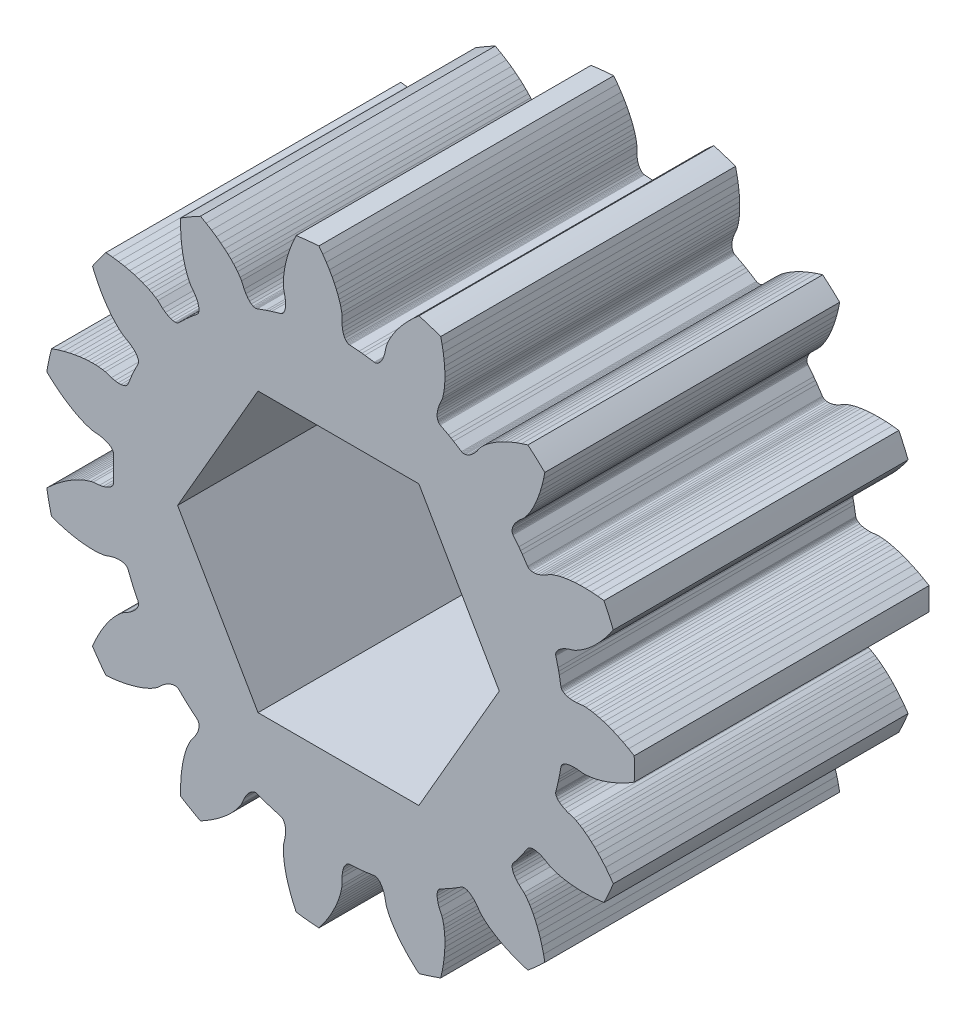
from build123d import *

# Parameters (mm, degrees)
BOSS_EXTRUDE1_DEPTH     = 6.35
CUT_EXTRUDE1_DEPTH      = 20.098065115
CUT_EXTRUDE1_DEPTH_BACK = 20.098065115


with BuildPart() as part:
    # Model → Boss-Extrude1 (new, symmetric)
    with BuildSketch(Plane.XY):
        with BuildLine():
            Line((11.6767396, 4.5035235), (11.5102774, 4.2884543))
            Line((11.5102774, 4.2884543), (11.3474436, 4.0953698))
            Line((11.3474436, 4.0953698), (11.189078, 3.9227721))
            Line((11.189078, 3.9227721), (11.0381832, 3.7714935))
            Line((11.0381832, 3.7714935), (10.8924568, 3.6371189))
            Line((10.8924568, 3.6371189), (10.7549211, 3.520628))
            Line((10.7549211, 3.520628), (10.6294039, 3.4230594))
            Line((10.6294039, 3.4230594), (10.5151057, 3.3415851))
            Line((10.5151057, 3.3415851), (10.4118689, 3.2743006))
            Line((10.4118689, 3.2743006), (10.2465352, 3.1803221))
            Line((10.2465352, 3.1803221), (10.1399378, 3.1308686))
            Line((10.1399378, 3.1308686), (9.8729831, 3.0466553))
            Line((9.8729831, 3.0466553), (9.731807, 2.9862021))
            Line((9.731807, 2.9862021), (9.6130244, 2.9201014))
            Line((9.6130244, 2.9201014), (9.516822, 2.8501205))
            Line((9.516822, 2.8501205), (9.4432844, 2.7780258))
            Line((9.4432844, 2.7780258), (9.3923921, 2.7055918))
            Line((9.3923921, 2.7055918), (9.3753911, 2.6698051))
            Line((9.3753911, 2.6698051), (9.3639924, 2.6345957))
            Line((9.3639924, 2.6345957), (9.3581623, 2.6001713))
            Line((9.3581623, 2.6001713), (9.3578605, 2.5667687))
            Line((9.3578605, 2.5667687), (9.3630336, 2.5345911))
            Line((9.3630336, 2.5345911), (9.460687, 2.1414942))
            Line((9.460687, 2.1414942), (9.4880317, 2.0167434))
            Line((9.4880317, 2.0167434), (9.5137918, 1.8916558))
            Line((9.5137918, 1.8916558), (9.5844679, 1.4928247))
            Line((9.5844679, 1.4928247), (9.5928298, 1.4613249))
            Line((9.5928298, 1.4613249), (9.6066916, 1.4309328))
            Line((9.6066916, 1.4309328), (9.6260194, 1.4018559))
            Line((9.6260194, 1.4018559), (9.6507535, 1.3743268))
            Line((9.6507535, 1.3743268), (9.6808405, 1.3485489))
            Line((9.6808405, 1.3485489), (9.7567944, 1.303077))
            Line((9.7567944, 1.303077), (9.853298, 1.2671256))
            Line((9.853298, 1.2671256), (9.969647, 1.2423239))
            Line((9.969647, 1.2423239), (10.1050459, 1.2302511))
            Line((10.1050459, 1.2302511), (10.2586052, 1.2324459))
            Line((10.2586052, 1.2324459), (10.5367331, 1.2640935))
            Line((10.5367331, 1.2640935), (10.6542293, 1.2622725))
            Line((10.6542293, 1.2622725), (10.8434936, 1.2436662))
            Line((10.8434936, 1.2436662), (10.9651721, 1.2241889))
            Line((10.9651721, 1.2241889), (11.1027273, 1.1962477))
            Line((11.1027273, 1.1962477), (11.2570777, 1.1581668))
            Line((11.2570777, 1.1581668), (11.4301039, 1.1076879))
            Line((11.4301039, 1.1076879), (11.6178867, 1.0442028))
            Line((11.6178867, 1.0442028), (11.8172666, 0.9673774))
            Line((11.8172666, 0.9673774), (12.0321425, 0.8741146))
            Line((12.0321425, 0.8741146), (12.2594331, 0.7639537))
            Line((12.2594331, 0.7639537), (12.4989804, 0.6351845))
            Line((12.4989804, 0.6351845), (12.740472, 0.4919755))
            ThreePointArc((12.740472, 0.4919755), (12.749967296, 0), (12.740472, -0.4919755))
            Line((12.740472, -0.4919755), (12.4989804, -0.6351845))
            Line((12.4989804, -0.6351845), (12.2594331, -0.7639537))
            Line((12.2594331, -0.7639537), (12.0321425, -0.8741146))
            Line((12.0321425, -0.8741146), (11.8172666, -0.9673774))
            Line((11.8172666, -0.9673774), (11.6178867, -1.0442028))
            Line((11.6178867, -1.0442028), (11.4301039, -1.1076879))
            Line((11.4301039, -1.1076879), (11.2570777, -1.1581668))
            Line((11.2570777, -1.1581668), (11.1027273, -1.1962477))
            Line((11.1027273, -1.1962477), (10.9651721, -1.2241889))
            Line((10.9651721, -1.2241889), (10.8434936, -1.2436662))
            Line((10.8434936, -1.2436662), (10.6542293, -1.2622725))
            Line((10.6542293, -1.2622725), (10.5367331, -1.2640935))
            Line((10.5367331, -1.2640935), (10.2586052, -1.2324459))
            Line((10.2586052, -1.2324459), (10.1050459, -1.2302511))
            Line((10.1050459, -1.2302511), (9.969647, -1.2423239))
            Line((9.969647, -1.2423239), (9.853298, -1.2671256))
            Line((9.853298, -1.2671256), (9.7567944, -1.303077))
            Line((9.7567944, -1.303077), (9.6808405, -1.3485489))
            Line((9.6808405, -1.3485489), (9.6507535, -1.3743268))
            Line((9.6507535, -1.3743268), (9.6260194, -1.4018559))
            Line((9.6260194, -1.4018559), (9.6066916, -1.4309328))
            Line((9.6066916, -1.4309328), (9.5928298, -1.4613249))
            Line((9.5928298, -1.4613249), (9.5844679, -1.4928247))
            Line((9.5844679, -1.4928247), (9.5137918, -1.8916558))
            Line((9.5137918, -1.8916558), (9.4880317, -2.0167434))
            Line((9.4880317, -2.0167434), (9.460687, -2.1414942))
            Line((9.460687, -2.1414942), (9.3630336, -2.5345911))
            Line((9.3630336, -2.5345911), (9.3578605, -2.5667687))
            Line((9.3578605, -2.5667687), (9.3581623, -2.6001713))
            Line((9.3581623, -2.6001713), (9.3639924, -2.6345957))
            Line((9.3639924, -2.6345957), (9.3753911, -2.6698051))
            Line((9.3753911, -2.6698051), (9.3923921, -2.7055918))
            Line((9.3923921, -2.7055918), (9.4432844, -2.7780258))
            Line((9.4432844, -2.7780258), (9.516822, -2.8501205))
            Line((9.516822, -2.8501205), (9.6130244, -2.9201014))
            Line((9.6130244, -2.9201014), (9.731807, -2.9862021))
            Line((9.731807, -2.9862021), (9.8729831, -3.0466553))
            Line((9.8729831, -3.0466553), (10.1399378, -3.1308686))
            Line((10.1399378, -3.1308686), (10.2465352, -3.1803221))
            Line((10.2465352, -3.1803221), (10.4118689, -3.2743006))
            Line((10.4118689, -3.2743006), (10.5151057, -3.3415851))
            Line((10.5151057, -3.3415851), (10.6294039, -3.4230594))
            Line((10.6294039, -3.4230594), (10.7549211, -3.520628))
            Line((10.7549211, -3.520628), (10.8924568, -3.6371189))
            Line((10.8924568, -3.6371189), (11.0381832, -3.7714935))
            Line((11.0381832, -3.7714935), (11.189078, -3.9227721))
            Line((11.189078, -3.9227721), (11.3474436, -4.0953698))
            Line((11.3474436, -4.0953698), (11.5102774, -4.2884543))
            Line((11.5102774, -4.2884543), (11.6767396, -4.5035235))
            Line((11.6767396, -4.5035235), (11.8391048, -4.7325748))
            ThreePointArc((11.8391048, -4.7325748), (11.647674735, -5.185878885), (11.4388959, -5.6314588))
            Line((11.4388959, -5.6314588), (11.160034, -5.6640632))
            Line((11.160034, -5.6640632), (10.8888215, -5.6842671))
            Line((10.8888215, -5.6842671), (10.6363747, -5.6924567))
            Line((10.6363747, -5.6924567), (10.4021424, -5.6902585))
            Line((10.4021424, -5.6902585), (10.1887521, -5.679347))
            Line((10.1887521, -5.679347), (9.9913823, -5.6609653))
            Line((9.9913823, -5.6609653), (9.8127834, -5.636704))
            Line((9.8127834, -5.636704), (9.6562884, -5.6087127))
            Line((9.6562884, -5.6087127), (9.5192607, -5.5782895))
            Line((9.5192607, -5.5782895), (9.4001797, -5.5465918))
            Line((9.4001797, -5.5465918), (9.2197103, -5.4866088))
            Line((9.2197103, -5.4866088), (9.1116315, -5.4404823))
            Line((9.1116315, -5.4404823), (8.8704213, -5.298446))
            Line((8.8704213, -5.298446), (8.7310306, -5.2339828))
            Line((8.7310306, -5.2339828), (8.6024271, -5.1899402))
            Line((8.6024271, -5.1899402), (8.4860492, -5.1652742))
            Line((8.4860492, -5.1652742), (8.3832661, -5.1588659))
            Line((8.3832661, -5.1588659), (8.2953836, -5.1695133))
            Line((8.2953836, -5.1695133), (8.257413, -5.1808251))
            Line((8.257413, -5.1808251), (8.2236201, -5.1959139))
            Line((8.2236201, -5.1959139), (8.1941367, -5.2146157))
            Line((8.1941367, -5.2146157), (8.1691117, -5.2367421))
            Line((8.1691117, -5.2367421), (8.1486606, -5.2621176))
            Line((8.1486606, -5.2621176), (7.9218756, -5.5977213))
            Line((7.9218756, -5.5977213), (7.8474648, -5.7015169))
            Line((7.8474648, -5.7015169), (7.7717435, -5.8043604))
            Line((7.7717435, -5.8043604), (7.5226458, -6.123753))
            Line((7.5226458, -6.123753), (7.5048321, -6.1510446))
            Line((7.5048321, -6.1510446), (7.4915217, -6.1816822))
            Line((7.4915217, -6.1816822), (7.4828461, -6.2155018))
            Line((7.4828461, -6.2155018), (7.4789384, -6.2523034))
            Line((7.4789384, -6.2523034), (7.4799138, -6.2919111))
            Line((7.4799138, -6.2919111), (7.4969447, -6.3787826))
            Line((7.4969447, -6.3787826), (7.5348011, -6.4745549))
            Line((7.5348011, -6.4745549), (7.5942226, -6.5776146))
            Line((7.5942226, -6.5776146), (7.6758502, -6.6863139))
            Line((7.6758502, -6.6863139), (7.7802325, -6.7989622))
            Line((7.7802325, -6.7989622), (7.9898551, -6.984475))
            Line((7.9898551, -6.984475), (8.0671222, -7.0730102))
            Line((8.0671222, -7.0730102), (8.1799375, -7.2261111))
            Line((8.1799375, -7.2261111), (8.246882, -7.3295686))
            Line((8.246882, -7.3295686), (8.31816, -7.4504884))
            Line((8.31816, -7.4504884), (8.3931409, -7.5906742))
            Line((8.3931409, -7.5906742), (8.4714049, -7.7530347))
            Line((8.4714049, -7.7530347), (8.5498775, -7.9350643))
            Line((8.5498775, -7.9350643), (8.6261962, -8.1346387))
            Line((8.6261962, -8.1346387), (8.7006686, -8.3567276))
            Line((8.7006686, -8.3567276), (8.7708902, -8.5993495))
            Line((8.7708902, -8.5993495), (8.8354844, -8.8635313))
            Line((8.8354844, -8.8635313), (8.8906488, -9.13882))
            ThreePointArc((8.8906488, -9.13882), (8.531393343, -9.47507223), (8.1594307, -9.7972117))
            Line((8.1594307, -9.7972117), (7.8914163, -9.713574))
            Line((7.8914163, -9.713574), (7.6354337, -9.6217191))
            Line((7.6354337, -9.6217191), (7.4014811, -9.5265213))
            Line((7.4014811, -9.5265213), (7.1883932, -9.4292423))
            Line((7.1883932, -9.4292423), (6.9978897, -9.3324805))
            Line((6.9978897, -9.3324805), (6.8250599, -9.2354105))
            Line((6.8250599, -9.2354105), (6.6717696, -9.1406039))
            Line((6.6717696, -9.1406039), (6.5401894, -9.0513803))
            Line((6.5401894, -9.0513803), (6.4273826, -8.9678532))
            Line((6.4273826, -8.9678532), (6.3314894, -8.8904613))
            Line((6.3314894, -8.8904613), (6.1910196, -8.7622605))
            Line((6.1910196, -8.7622605), (6.1110461, -8.6761623))
            Line((6.1110461, -8.6761623), (5.948461, -8.4482966))
            Line((5.948461, -8.4482966), (5.8473407, -8.3327113))
            Line((5.8473407, -8.3327113), (5.7477694, -8.2401686))
            Line((5.7477694, -8.2401686), (5.6514854, -8.1702999))
            Line((5.6514854, -8.1702999), (5.5601949, -8.12264))
            Line((5.5601949, -8.12264), (5.4755795, -8.0966219))
            Line((5.4755795, -8.0966219), (5.4362907, -8.0915117))
            Line((5.4362907, -8.0915117), (5.3992822, -8.0915512))
            Line((5.3992822, -8.0915512), (5.3647411, -8.0966441))
            Line((5.3647411, -8.0966441), (5.33288, -8.1066791))
            Line((5.33288, -8.1066791), (5.3038758, -8.1215424))
            Line((5.3038758, -8.1215424), (4.9601951, -8.3358899))
            Line((4.9601951, -8.3358899), (4.85, -8.4004464))
            Line((4.85, -8.4004464), (4.7389949, -8.4635999))
            Line((4.7389949, -8.4635999), (4.3815242, -8.6540624))
            Line((4.3815242, -8.6540624), (4.35415, -8.6717491))
            Line((4.35415, -8.6717491), (4.3295289, -8.6943241))
            Line((4.3295289, -8.6943241), (4.3078478, -8.7216912))
            Line((4.3078478, -8.7216912), (4.2893093, -8.7537217))
            Line((4.2893093, -8.7537217), (4.2740905, -8.7903019))
            Line((4.2740905, -8.7903019), (4.2543151, -8.87659))
            Line((4.2543151, -8.87659), (4.2499446, -8.9794799))
            Line((4.2499446, -8.9794799), (4.2623106, -9.0977986))
            Line((4.2623106, -9.0977986), (4.2926693, -9.2303013))
            Line((4.2926693, -9.2303013), (4.342209, -9.3756666))
            Line((4.342209, -9.3756666), (4.4582539, -9.6304023))
            Line((4.4582539, -9.6304023), (4.4928304, -9.7427105))
            Line((4.4928304, -9.7427105), (4.5336206, -9.9284613))
            Line((4.5336206, -9.9284613), (4.5526974, -10.0502032))
            Line((4.5526974, -10.0502032), (4.5686306, -10.1896603))
            Line((4.5686306, -10.1896603), (4.5801104, -10.3482239))
            Line((4.5801104, -10.3482239), (4.5855701, -10.5283805))
            Line((4.5855701, -10.5283805), (4.5832203, -10.7265905))
            Line((4.5832203, -10.7265905), (4.5717668, -10.9399523))
            Line((4.5717668, -10.9399523), (4.5494689, -11.1731313))
            Line((4.5494689, -11.1731313), (4.5149363, -11.4233391))
            Line((4.5149363, -11.4233391), (4.4664937, -11.690954))
            Line((4.4664937, -11.690954), (4.4049189, -11.9648801))
            ThreePointArc((4.4049189, -11.9648801), (3.939956558, -12.125939465), (3.4691258, -12.2689377))
            Line((3.4691258, -12.2689377), (3.258301, -12.0835196))
            Line((3.258301, -12.0835196), (3.06181, -11.8954884))
            Line((3.06181, -11.8954884), (2.8868041, -11.7133638))
            Line((2.8868041, -11.7133638), (2.7317056, -11.5378244))
            Line((2.7317056, -11.5378244), (2.5970286, -11.3719433))
            Line((2.5970286, -11.3719433), (2.4786226, -11.2129692))
            Line((2.4786226, -11.2129692), (2.3771463, -11.0640104))
            Line((2.3771463, -11.0640104), (2.2932323, -10.9289821))
            Line((2.2932323, -10.9289821), (2.2241517, -10.8067936))
            Line((2.2241517, -10.8067936), (2.168027, -10.6970892))
            Line((2.168027, -10.6970892), (2.0918454, -10.5228378))
            Line((2.0918454, -10.5228378), (2.0538053, -10.411655))
            Line((2.0538053, -10.411655), (1.9979577, -10.1373601))
            Line((1.9979577, -10.1373601), (1.9525926, -9.9906383))
            Line((1.9525926, -9.9906383), (1.8992701, -9.865597))
            Line((1.8992701, -9.865597), (1.8397285, -9.7626066))
            Line((1.8397285, -9.7626066), (1.7757154, -9.6819359))
            Line((1.7757154, -9.6819359), (1.708998, -9.623751))
            Line((1.708998, -9.623751), (1.6751844, -9.6031024))
            Line((1.6751844, -9.6031024), (1.6413594, -9.5880858))
            Line((1.6413594, -9.5880858), (1.607733, -9.5786892))
            Line((1.607733, -9.5786892), (1.5745448, -9.5748975))
            Line((1.5745448, -9.5748975), (1.5420028, -9.5766789))
            Line((1.5420028, -9.5766789), (1.1408518, -9.6327075))
            Line((1.1408518, -9.6327075), (1.0139261, -9.6468624))
            Line((1.0139261, -9.6468624), (0.886831, -9.6594062))
            Line((0.886831, -9.6594062), (0.4827972, -9.6880059))
            Line((0.4827972, -9.6880059), (0.4505959, -9.6930293))
            Line((0.4505959, -9.6930293), (0.4189213, -9.7036383))
            Line((0.4189213, -9.7036383), (0.3879834, -9.7198209))
            Line((0.3879834, -9.7198209), (0.3580197, -9.7415419))
            Line((0.3580197, -9.7415419), (0.3292381, -9.7687696))
            Line((0.3292381, -9.7687696), (0.2760759, -9.8395543))
            Line((0.2760759, -9.8395543), (0.230234, -9.9317713))
            Line((0.230234, -9.9317713), (0.1934065, -10.0448905))
            Line((0.1934065, -10.0448905), (0.1672468, -10.1782857))
            Line((0.1672468, -10.1782857), (0.1533782, -10.3312332))
            Line((0.1533782, -10.3312332), (0.1557801, -10.6111455))
            Line((0.1557801, -10.6111455), (0.1416874, -10.7278077))
            Line((0.1416874, -10.7278077), (0.1033995, -10.9140903))
            Line((0.1033995, -10.9140903), (0.0713101, -11.0330664))
            Line((0.0713101, -11.0330664), (0.0291435, -11.1669474))
            Line((0.0291435, -11.1669474), (-0.0248628, -11.3164717))
            Line((-0.0248628, -11.3164717), (-0.0931514, -11.4832735))
            Line((-0.0931514, -11.4832735), (-0.1759173, -11.6633916))
            Line((-0.1759173, -11.6633916), (-0.2731627, -11.8536488))
            Line((-0.2731627, -11.8536488), (-0.3883753, -12.0575991))
            Line((-0.3883753, -12.0575991), (-0.521691, -12.2721296))
            Line((-0.521691, -12.2721296), (-0.6747944, -12.4969046))
            Line((-0.6747944, -12.4969046), (-0.8424615, -12.7221038))
            ThreePointArc((-0.8424615, -12.7221038), (-1.332734479, -12.680121632), (-1.8210224, -12.6192529))
            Line((-1.8210224, -12.6192529), (-1.9382041, -12.3641149))
            Line((-1.9382041, -12.3641149), (-2.0412284, -12.1124198))
            Line((-2.0412284, -12.1124198), (-2.1270275, -11.8748593))
            Line((-2.1270275, -11.8748593), (-2.1973187, -11.6514119))
            Line((-2.1973187, -11.6514119), (-2.2528824, -11.4450938))
            Line((-2.2528824, -11.4450938), (-2.296391, -11.2517037))
            Line((-2.296391, -11.2517037), (-2.3285073, -11.0743489))
            Line((-2.3285073, -11.0743489), (-2.3502456, -10.9168635))
            Line((-2.3502456, -10.9168635), (-2.3636553, -10.7771412))
            Line((-2.3636553, -10.7771412), (-2.370307, -10.6540933))
            Line((-2.370307, -10.6540933), (-2.3690279, -10.4639209))
            Line((-2.3690279, -10.4639209), (-2.3585571, -10.346878))
            Line((-2.3585571, -10.346878), (-2.2980106, -10.0735819))
            Line((-2.2980106, -10.0735819), (-2.2797766, -9.9210931))
            Line((-2.2797766, -9.9210931), (-2.2776302, -9.7851741))
            Line((-2.2776302, -9.7851741), (-2.2901342, -9.6668699))
            Line((-2.2901342, -9.6668699), (-2.3158013, -9.5671371))
            Line((-2.3158013, -9.5671371), (-2.3530848, -9.4868461))
            Line((-2.3530848, -9.4868461), (-2.3755765, -9.4542294))
            Line((-2.3755765, -9.4542294), (-2.4003694, -9.4267532))
            Line((-2.4003694, -9.4267532), (-2.4272667, -9.4044919))
            Line((-2.4272667, -9.4044919), (-2.4560434, -9.3875292))
            Line((-2.4560434, -9.3875292), (-2.4864966, -9.3759205))
            Line((-2.4864966, -9.3759205), (-2.8757551, -9.2639424))
            Line((-2.8757551, -9.2639424), (-2.9974648, -9.2252482))
            Line((-2.9974648, -9.2252482), (-3.118674, -9.1850133))
            Line((-3.118674, -9.1850133), (-3.4994098, -9.0468051))
            Line((-3.4994098, -9.0468051), (-3.5308704, -9.0382968))
            Line((-3.5308704, -9.0382968), (-3.5641216, -9.0351054))
            Line((-3.5641216, -9.0351054), (-3.5989669, -9.0373053))
            Line((-3.5989669, -9.0373053), (-3.6351748, -9.0449611))
            Line((-3.6351748, -9.0449611), (-3.6725426, -9.0581283))
            Line((-3.6725426, -9.0581283), (-3.7498994, -9.1011703))
            Line((-3.7498994, -9.1011703), (-3.8292861, -9.1667692))
            Line((-3.8292861, -9.1667692), (-3.9089394, -9.2551296))
            Line((-3.9089394, -9.2551296), (-3.9870942, -9.366352))
            Line((-3.9870942, -9.366352), (-4.0619732, -9.5004357))
            Line((-4.0619732, -9.5004357), (-4.1736295, -9.7571253))
            Line((-4.1736295, -9.7571253), (-4.2339546, -9.8579694))
            Line((-4.2339546, -9.8579694), (-4.3447003, -10.012574))
            Line((-4.3447003, -10.012574), (-4.4224073, -10.1082121))
            Line((-4.4224073, -10.1082121), (-4.5153828, -10.2133678))
            Line((-4.5153828, -10.2133678), (-4.625537, -10.3279987))
            Line((-4.625537, -10.3279987), (-4.7557661, -10.4526043))
            Line((-4.7557661, -10.4526043), (-4.9046372, -10.5834864))
            Line((-4.9046372, -10.5834864), (-5.0708599, -10.7177417))
            Line((-5.0708599, -10.7177417), (-5.2590658, -10.8571984))
            Line((-5.2590658, -10.8571984), (-5.4681133, -10.9989574))
            Line((-5.4681133, -10.9989574), (-5.6994043, -11.1420268))
            Line((-5.6994043, -11.1420268), (-5.9441727, -11.2795602))
            ThreePointArc((-5.9441727, -11.2795602), (-6.374983648, -11.041795618), (-6.7962993, -10.7875847))
            Line((-6.7962993, -10.7875847), (-6.7995761, -10.5068423))
            Line((-6.7995761, -10.5068423), (-6.7913199, -10.2350037))
            Line((-6.7913199, -10.2350037), (-6.7730767, -9.9830838))
            Line((-6.7730767, -9.9830838), (-6.7464067, -9.7503643))
            Line((-6.7464067, -9.7503643), (-6.7132495, -9.5392836))
            Line((-6.7132495, -9.5392836), (-6.6743378, -9.3449164))
            Line((-6.6743378, -9.3449164), (-6.6315407, -9.1698319))
            Line((-6.6315407, -9.1698319), (-6.5873446, -9.0171201))
            Line((-6.5873446, -9.0171201), (-6.5427648, -8.8840231))
            Line((-6.5427648, -8.8840231), (-6.4987933, -8.7689078))
            Line((-6.4987933, -8.7689078), (-6.4202747, -8.5956969))
            Line((-6.4202747, -8.5956969), (-6.3631036, -8.4930318))
            Line((-6.3631036, -8.4930318), (-6.196632, -8.2679898))
            Line((-6.196632, -8.2679898), (-6.1179517, -8.1361009))
            Line((-6.1179517, -8.1361009), (-6.0607076, -8.0128056))
            Line((-6.0607076, -8.0128056), (-6.0240119, -7.8996436))
            Line((-6.0240119, -7.8996436), (-6.006895, -7.7980933))
            Line((-6.006895, -7.7980933), (-6.0082979, -7.7095793))
            Line((-6.0082979, -7.7095793), (-6.0155787, -7.6706343))
            Line((-6.0155787, -7.6706343), (-6.0270525, -7.6354494))
            Line((-6.0270525, -7.6354494), (-6.04257, -7.6041726))
            Line((-6.04257, -7.6041726), (-6.0619594, -7.5769719))
            Line((-6.0619594, -7.5769719), (-6.0850581, -7.5539803))
            Line((-6.0850581, -7.5539803), (-6.3951179, -7.2933575))
            Line((-6.3951179, -7.2933575), (-6.4905669, -7.2085048))
            Line((-6.4905669, -7.2085048), (-6.5849319, -7.1224482))
            Line((-6.5849319, -7.1224482), (-6.8765371, -6.8413295))
            Line((-6.8765371, -6.8413295), (-6.9018171, -6.8207606))
            Line((-6.9018171, -6.8207606), (-6.9308956, -6.8043206))
            Line((-6.9308956, -6.8043206), (-6.9636231, -6.7921575))
            Line((-6.9636231, -6.7921575), (-6.9998146, -6.7844243))
            Line((-6.9998146, -6.7844243), (-7.0393073, -6.7812543))
            Line((-7.0393073, -6.7812543), (-7.1274831, -6.7891113))
            Line((-7.1274831, -6.7891113), (-7.2266878, -6.8167494))
            Line((-7.2266878, -6.8167494), (-7.3353942, -6.8650727))
            Line((-7.3353942, -6.8650727), (-7.4520304, -6.934891))
            Line((-7.4520304, -6.934891), (-7.5749725, -7.0269265))
            Line((-7.5749725, -7.0269265), (-7.7813806, -7.2160094))
            Line((-7.7813806, -7.2160094), (-7.8775074, -7.2835987))
            Line((-7.8775074, -7.2835987), (-8.041562, -7.3797927))
            Line((-8.041562, -7.3797927), (-8.1514504, -7.4355561))
            Line((-8.1514504, -7.4355561), (-8.2791584, -7.4938041))
            Line((-8.2791584, -7.4938041), (-8.4264138, -7.5537209))
            Line((-8.4264138, -7.5537209), (-8.5960657, -7.6145848))
            Line((-8.5960657, -7.6145848), (-8.7853008, -7.6736003))
            Line((-8.7853008, -7.6736003), (-8.9917593, -7.7286398))
            Line((-8.9917593, -7.7286398), (-9.2204161, -7.7794895))
            Line((-9.2204161, -7.7794895), (-9.469049, -7.8239655))
            Line((-9.469049, -7.8239655), (-9.7385355, -7.8605914))
            Line((-9.7385355, -7.8605914), (-10.0180824, -7.8866781))
            ThreePointArc((-10.0180824, -7.8866781), (-10.314940206, -7.494242745), (-10.5964343, -7.090645))
            Line((-10.5964343, -7.090645), (-10.4852396, -6.8328413))
            Line((-10.4852396, -6.8328413), (-10.3671305, -6.5878625))
            Line((-10.3671305, -6.5878625), (-10.2479995, -6.3651424))
            Line((-10.2479995, -6.3651424), (-10.1289796, -6.1633903))
            Line((-10.1289796, -6.1633903), (-10.0128348, -5.9840447))
            Line((-10.0128348, -5.9840447), (-9.8982309, -5.8223082))
            Line((-9.8982309, -5.8223082), (-9.7879206, -5.6797677))
            Line((-9.7879206, -5.6797677), (-9.6854319, -5.5582347))
            Line((-9.6854319, -5.5582347), (-9.5905708, -5.4547768))
            Line((-9.5905708, -5.4547768), (-9.5035793, -5.3674986))
            Line((-9.5035793, -5.3674986), (-9.3613977, -5.2411989))
            Line((-9.3613977, -5.2411989), (-9.2674116, -5.1706632))
            Line((-9.2674116, -5.1706632), (-9.0237995, -5.0327872))
            Line((-9.0237995, -5.0327872), (-8.8982773, -4.9443029))
            Line((-8.8982773, -4.9443029), (-8.7958336, -4.8549503))
            Line((-8.7958336, -4.8549503), (-8.7162832, -4.7664971))
            Line((-8.7162832, -4.7664971), (-8.6593419, -4.6806884))
            Line((-8.6593419, -4.6806884), (-8.6246217, -4.5992563))
            Line((-8.6246217, -4.5992563), (-8.6154326, -4.5607168))
            Line((-8.6154326, -4.5607168), (-8.6116035, -4.523907))
            Line((-8.6116035, -4.523907), (-8.613058, -4.4890227))
            Line((-8.613058, -4.4890227), (-8.6197076, -4.4562872))
            Line((-8.6197076, -4.4562872), (-8.6314578, -4.4258883))
            Line((-8.6314578, -4.4258883), (-8.8087066, -4.0616849))
            Line((-8.8087066, -4.0616849), (-8.8613909, -3.9453454))
            Line((-8.8613909, -3.9453454), (-8.9125953, -3.8283471))
            Line((-8.9125953, -3.8283471), (-9.0646486, -3.4529259))
            Line((-9.0646486, -3.4529259), (-9.0793769, -3.4238529))
            Line((-9.0793769, -3.4238529), (-9.0992547, -3.397007))
            Line((-9.0992547, -3.397007), (-9.1242055, -3.3725839))
            Line((-9.1242055, -3.3725839), (-9.1541228, -3.350799))
            Line((-9.1541228, -3.350799), (-9.1889118, -3.3318398))
            Line((-9.1889118, -3.3318398), (-9.2726601, -3.3031533))
            Line((-9.2726601, -3.3031533), (-9.3745296, -3.2880517))
            Line((-9.3745296, -3.2880517), (-9.4934927, -3.2879823))
            Line((-9.4934927, -3.2879823), (-9.6284428, -3.3043244))
            Line((-9.6284428, -3.3043244), (-9.7781902, -3.3383979))
            Line((-9.7781902, -3.3383979), (-10.0436604, -3.42718))
            Line((-10.0436604, -3.42718), (-10.1589676, -3.4498276))
            Line((-10.1589676, -3.4498276), (-10.3479645, -3.4709782))
            Line((-10.3479645, -3.4709782), (-10.4710336, -3.477225))
            Line((-10.4710336, -3.477225), (-10.6113922, -3.4784936))
            Line((-10.6113922, -3.4784936), (-10.7702872, -3.4733361))
            Line((-10.7702872, -3.4733361), (-10.9500275, -3.4599345))
            Line((-10.9500275, -3.4599345), (-11.1469061, -3.4368789))
            Line((-11.1469061, -3.4368789), (-11.3579019, -3.4031857))
            Line((-11.3579019, -3.4031857), (-11.5874727, -3.3566362))
            Line((-11.5874727, -3.3566362), (-11.8327002, -3.2961389))
            Line((-11.8327002, -3.2961389), (-12.0937854, -3.2199883))
            Line((-12.0937854, -3.2199883), (-12.3597747, -3.1301177))
            ThreePointArc((-12.3597747, -3.1301177), (-12.471349951, -2.650867233), (-12.5643496, -2.1676684))
            Line((-12.5643496, -2.1676684), (-12.35791, -1.97738))
            Line((-12.35791, -1.97738), (-12.15037, -1.80162))
            Line((-12.15037, -1.80162), (-11.95095, -1.64661))
            Line((-11.95095, -1.64661), (-11.76016, -1.51071))
            Line((-11.76016, -1.51071), (-11.58111, -1.39411))
            Line((-11.58111, -1.39411), (-11.41063, -1.29297))
            Line((-11.41063, -1.29297), (-11.25188, -1.20762))
            Line((-11.25188, -1.20762), (-11.10882, -1.13828))
            Line((-11.10882, -1.13828), (-10.98008, -1.08235))
            Line((-10.98008, -1.08235), (-10.86511, -1.038))
            Line((-10.86511, -1.038), (-10.68385, -0.98045))
            Line((-10.68385, -0.98045), (-10.5693, -0.95424))
            Line((-10.5693, -0.95424), (-10.29067, -0.92737))
            Line((-10.29067, -0.92737), (-10.14001, -0.89759))
            Line((-10.14001, -0.89759), (-10.01008, -0.85763))
            Line((-10.01008, -0.85763), (-9.90143, -0.80918))
            Line((-9.90143, -0.80918), (-9.81451, -0.75395))
            Line((-9.81451, -0.75395), (-9.74967, -0.69368))
            Line((-9.74967, -0.69368), (-9.7256, -0.66221))
            Line((-9.7256, -0.66221), (-9.70713, -0.63014))
            Line((-9.70713, -0.63014), (-9.69427, -0.59768))
            Line((-9.69427, -0.59768), (-9.68703, -0.56507))
            Line((-9.68703, -0.56507), (-9.6854, -0.53252))
            Line((-9.6854, -0.53252), (-9.69919, -0.12771))
            Line((-9.69919, -0.12771), (-9.7, 0))
            Line((-9.7, 0), (-9.69919, 0.12771))
            Line((-9.69919, 0.12771), (-9.6854, 0.53252))
            Line((-9.6854, 0.53252), (-9.68703, 0.56507))
            Line((-9.68703, 0.56507), (-9.69427, 0.59768))
            Line((-9.69427, 0.59768), (-9.70713, 0.63014))
            Line((-9.70713, 0.63014), (-9.7256, 0.66221))
            Line((-9.7256, 0.66221), (-9.74967, 0.69368))
            Line((-9.74967, 0.69368), (-9.81451, 0.75395))
            Line((-9.81451, 0.75395), (-9.90143, 0.80918))
            Line((-9.90143, 0.80918), (-10.01008, 0.85763))
            Line((-10.01008, 0.85763), (-10.14001, 0.89759))
            Line((-10.14001, 0.89759), (-10.29067, 0.92737))
            Line((-10.29067, 0.92737), (-10.5693, 0.95424))
            Line((-10.5693, 0.95424), (-10.68385, 0.98045))
            Line((-10.68385, 0.98045), (-10.86511, 1.038))
            Line((-10.86511, 1.038), (-10.98008, 1.08235))
            Line((-10.98008, 1.08235), (-11.10882, 1.13828))
            Line((-11.10882, 1.13828), (-11.25188, 1.20762))
            Line((-11.25188, 1.20762), (-11.41063, 1.29297))
            Line((-11.41063, 1.29297), (-11.58111, 1.39411))
            Line((-11.58111, 1.39411), (-11.76016, 1.51071))
            Line((-11.76016, 1.51071), (-11.95095, 1.64661))
            Line((-11.95095, 1.64661), (-12.15037, 1.80162))
            Line((-12.15037, 1.80162), (-12.35791, 1.97738))
            Line((-12.35791, 1.97738), (-12.5643496, 2.1676684))
            ThreePointArc((-12.5643496, 2.1676684), (-12.471349951, 2.650867233), (-12.3597747, 3.1301177))
            Line((-12.3597747, 3.1301177), (-12.0937854, 3.2199883))
            Line((-12.0937854, 3.2199883), (-11.8327002, 3.2961389))
            Line((-11.8327002, 3.2961389), (-11.5874727, 3.3566362))
            Line((-11.5874727, 3.3566362), (-11.3579019, 3.4031857))
            Line((-11.3579019, 3.4031857), (-11.1469061, 3.4368789))
            Line((-11.1469061, 3.4368789), (-10.9500275, 3.4599345))
            Line((-10.9500275, 3.4599345), (-10.7702872, 3.4733361))
            Line((-10.7702872, 3.4733361), (-10.6113922, 3.4784936))
            Line((-10.6113922, 3.4784936), (-10.4710336, 3.477225))
            Line((-10.4710336, 3.477225), (-10.3479645, 3.4709782))
            Line((-10.3479645, 3.4709782), (-10.1589676, 3.4498276))
            Line((-10.1589676, 3.4498276), (-10.0436604, 3.42718))
            Line((-10.0436604, 3.42718), (-9.7781902, 3.3383979))
            Line((-9.7781902, 3.3383979), (-9.6284428, 3.3043244))
            Line((-9.6284428, 3.3043244), (-9.4934927, 3.2879823))
            Line((-9.4934927, 3.2879823), (-9.3745296, 3.2880517))
            Line((-9.3745296, 3.2880517), (-9.2726601, 3.3031533))
            Line((-9.2726601, 3.3031533), (-9.1889118, 3.3318398))
            Line((-9.1889118, 3.3318398), (-9.1541228, 3.350799))
            Line((-9.1541228, 3.350799), (-9.1242055, 3.3725839))
            Line((-9.1242055, 3.3725839), (-9.0992547, 3.397007))
            Line((-9.0992547, 3.397007), (-9.0793769, 3.4238529))
            Line((-9.0793769, 3.4238529), (-9.0646486, 3.4529259))
            Line((-9.0646486, 3.4529259), (-8.9125953, 3.8283471))
            Line((-8.9125953, 3.8283471), (-8.8613909, 3.9453454))
            Line((-8.8613909, 3.9453454), (-8.8087066, 4.0616849))
            Line((-8.8087066, 4.0616849), (-8.6314578, 4.4258883))
            Line((-8.6314578, 4.4258883), (-8.6197076, 4.4562872))
            Line((-8.6197076, 4.4562872), (-8.613058, 4.4890227))
            Line((-8.613058, 4.4890227), (-8.6116035, 4.523907))
            Line((-8.6116035, 4.523907), (-8.6154326, 4.5607168))
            Line((-8.6154326, 4.5607168), (-8.6246217, 4.5992563))
            Line((-8.6246217, 4.5992563), (-8.6593419, 4.6806884))
            Line((-8.6593419, 4.6806884), (-8.7162832, 4.7664971))
            Line((-8.7162832, 4.7664971), (-8.7958336, 4.8549503))
            Line((-8.7958336, 4.8549503), (-8.8982773, 4.9443029))
            Line((-8.8982773, 4.9443029), (-9.0237995, 5.0327872))
            Line((-9.0237995, 5.0327872), (-9.2674116, 5.1706632))
            Line((-9.2674116, 5.1706632), (-9.3613977, 5.2411989))
            Line((-9.3613977, 5.2411989), (-9.5035793, 5.3674986))
            Line((-9.5035793, 5.3674986), (-9.5905708, 5.4547768))
            Line((-9.5905708, 5.4547768), (-9.6854319, 5.5582347))
            Line((-9.6854319, 5.5582347), (-9.7879206, 5.6797677))
            Line((-9.7879206, 5.6797677), (-9.8982309, 5.8223082))
            Line((-9.8982309, 5.8223082), (-10.0128348, 5.9840447))
            Line((-10.0128348, 5.9840447), (-10.1289796, 6.1633903))
            Line((-10.1289796, 6.1633903), (-10.2479995, 6.3651424))
            Line((-10.2479995, 6.3651424), (-10.3671305, 6.5878625))
            Line((-10.3671305, 6.5878625), (-10.4852396, 6.8328413))
            Line((-10.4852396, 6.8328413), (-10.5964343, 7.090645))
            ThreePointArc((-10.5964343, 7.090645), (-10.314940206, 7.494242745), (-10.0180824, 7.8866781))
            Line((-10.0180824, 7.8866781), (-9.7385355, 7.8605914))
            Line((-9.7385355, 7.8605914), (-9.469049, 7.8239655))
            Line((-9.469049, 7.8239655), (-9.2204161, 7.7794895))
            Line((-9.2204161, 7.7794895), (-8.9917593, 7.7286398))
            Line((-8.9917593, 7.7286398), (-8.7853008, 7.6736003))
            Line((-8.7853008, 7.6736003), (-8.5960657, 7.6145848))
            Line((-8.5960657, 7.6145848), (-8.4264138, 7.5537209))
            Line((-8.4264138, 7.5537209), (-8.2791584, 7.4938041))
            Line((-8.2791584, 7.4938041), (-8.1514504, 7.4355561))
            Line((-8.1514504, 7.4355561), (-8.041562, 7.3797927))
            Line((-8.041562, 7.3797927), (-7.8775074, 7.2835987))
            Line((-7.8775074, 7.2835987), (-7.7813806, 7.2160094))
            Line((-7.7813806, 7.2160094), (-7.5749725, 7.0269265))
            Line((-7.5749725, 7.0269265), (-7.4520304, 6.934891))
            Line((-7.4520304, 6.934891), (-7.3353942, 6.8650727))
            Line((-7.3353942, 6.8650727), (-7.2266878, 6.8167494))
            Line((-7.2266878, 6.8167494), (-7.1274831, 6.7891113))
            Line((-7.1274831, 6.7891113), (-7.0393073, 6.7812543))
            Line((-7.0393073, 6.7812543), (-6.9998146, 6.7844243))
            Line((-6.9998146, 6.7844243), (-6.9636231, 6.7921575))
            Line((-6.9636231, 6.7921575), (-6.9308956, 6.8043206))
            Line((-6.9308956, 6.8043206), (-6.9018171, 6.8207606))
            Line((-6.9018171, 6.8207606), (-6.8765371, 6.8413295))
            Line((-6.8765371, 6.8413295), (-6.5849319, 7.1224482))
            Line((-6.5849319, 7.1224482), (-6.4905669, 7.2085048))
            Line((-6.4905669, 7.2085048), (-6.3951179, 7.2933575))
            Line((-6.3951179, 7.2933575), (-6.0850581, 7.5539803))
            Line((-6.0850581, 7.5539803), (-6.0619594, 7.5769719))
            Line((-6.0619594, 7.5769719), (-6.04257, 7.6041726))
            Line((-6.04257, 7.6041726), (-6.0270525, 7.6354494))
            Line((-6.0270525, 7.6354494), (-6.0155787, 7.6706343))
            Line((-6.0155787, 7.6706343), (-6.0082979, 7.7095793))
            Line((-6.0082979, 7.7095793), (-6.006895, 7.7980933))
            Line((-6.006895, 7.7980933), (-6.0240119, 7.8996436))
            Line((-6.0240119, 7.8996436), (-6.0607076, 8.0128056))
            Line((-6.0607076, 8.0128056), (-6.1179517, 8.1361009))
            Line((-6.1179517, 8.1361009), (-6.196632, 8.2679898))
            Line((-6.196632, 8.2679898), (-6.3631036, 8.4930318))
            Line((-6.3631036, 8.4930318), (-6.4202747, 8.5956969))
            Line((-6.4202747, 8.5956969), (-6.4987933, 8.7689078))
            Line((-6.4987933, 8.7689078), (-6.5427648, 8.8840231))
            Line((-6.5427648, 8.8840231), (-6.5873446, 9.0171201))
            Line((-6.5873446, 9.0171201), (-6.6315407, 9.1698319))
            Line((-6.6315407, 9.1698319), (-6.6743378, 9.3449164))
            Line((-6.6743378, 9.3449164), (-6.7132495, 9.5392836))
            Line((-6.7132495, 9.5392836), (-6.7464067, 9.7503643))
            Line((-6.7464067, 9.7503643), (-6.7730767, 9.9830838))
            Line((-6.7730767, 9.9830838), (-6.7913199, 10.2350037))
            Line((-6.7913199, 10.2350037), (-6.7995761, 10.5068423))
            Line((-6.7995761, 10.5068423), (-6.7962993, 10.7875847))
            ThreePointArc((-6.7962993, 10.7875847), (-6.374983648, 11.041795618), (-5.9441727, 11.2795602))
            Line((-5.9441727, 11.2795602), (-5.6994043, 11.1420268))
            Line((-5.6994043, 11.1420268), (-5.4681133, 10.9989574))
            Line((-5.4681133, 10.9989574), (-5.2590658, 10.8571984))
            Line((-5.2590658, 10.8571984), (-5.0708599, 10.7177417))
            Line((-5.0708599, 10.7177417), (-4.9046372, 10.5834864))
            Line((-4.9046372, 10.5834864), (-4.7557661, 10.4526043))
            Line((-4.7557661, 10.4526043), (-4.625537, 10.3279987))
            Line((-4.625537, 10.3279987), (-4.5153828, 10.2133678))
            Line((-4.5153828, 10.2133678), (-4.4224073, 10.1082121))
            Line((-4.4224073, 10.1082121), (-4.3447003, 10.012574))
            Line((-4.3447003, 10.012574), (-4.2339546, 9.8579694))
            Line((-4.2339546, 9.8579694), (-4.1736295, 9.7571253))
            Line((-4.1736295, 9.7571253), (-4.0619732, 9.5004357))
            Line((-4.0619732, 9.5004357), (-3.9870942, 9.366352))
            Line((-3.9870942, 9.366352), (-3.9089394, 9.2551296))
            Line((-3.9089394, 9.2551296), (-3.8292861, 9.1667692))
            Line((-3.8292861, 9.1667692), (-3.7498994, 9.1011703))
            Line((-3.7498994, 9.1011703), (-3.6725426, 9.0581283))
            Line((-3.6725426, 9.0581283), (-3.6351748, 9.0449611))
            Line((-3.6351748, 9.0449611), (-3.5989669, 9.0373053))
            Line((-3.5989669, 9.0373053), (-3.5641216, 9.0351054))
            Line((-3.5641216, 9.0351054), (-3.5308704, 9.0382968))
            Line((-3.5308704, 9.0382968), (-3.4994098, 9.0468051))
            Line((-3.4994098, 9.0468051), (-3.118674, 9.1850133))
            Line((-3.118674, 9.1850133), (-2.9974648, 9.2252482))
            Line((-2.9974648, 9.2252482), (-2.8757551, 9.2639424))
            Line((-2.8757551, 9.2639424), (-2.4864966, 9.3759205))
            Line((-2.4864966, 9.3759205), (-2.4560434, 9.3875292))
            Line((-2.4560434, 9.3875292), (-2.4272667, 9.4044919))
            Line((-2.4272667, 9.4044919), (-2.4003694, 9.4267532))
            Line((-2.4003694, 9.4267532), (-2.3755765, 9.4542294))
            Line((-2.3755765, 9.4542294), (-2.3530848, 9.4868461))
            Line((-2.3530848, 9.4868461), (-2.3158013, 9.5671371))
            Line((-2.3158013, 9.5671371), (-2.2901342, 9.6668699))
            Line((-2.2901342, 9.6668699), (-2.2776302, 9.7851741))
            Line((-2.2776302, 9.7851741), (-2.2797766, 9.9210931))
            Line((-2.2797766, 9.9210931), (-2.2980106, 10.0735819))
            Line((-2.2980106, 10.0735819), (-2.3585571, 10.346878))
            Line((-2.3585571, 10.346878), (-2.3690279, 10.4639209))
            Line((-2.3690279, 10.4639209), (-2.370307, 10.6540933))
            Line((-2.370307, 10.6540933), (-2.3636553, 10.7771412))
            Line((-2.3636553, 10.7771412), (-2.3502456, 10.9168635))
            Line((-2.3502456, 10.9168635), (-2.3285073, 11.0743489))
            Line((-2.3285073, 11.0743489), (-2.296391, 11.2517037))
            Line((-2.296391, 11.2517037), (-2.2528824, 11.4450938))
            Line((-2.2528824, 11.4450938), (-2.1973187, 11.6514119))
            Line((-2.1973187, 11.6514119), (-2.1270275, 11.8748593))
            Line((-2.1270275, 11.8748593), (-2.0412284, 12.1124198))
            Line((-2.0412284, 12.1124198), (-1.9382041, 12.3641149))
            Line((-1.9382041, 12.3641149), (-1.8210224, 12.6192529))
            ThreePointArc((-1.8210224, 12.6192529), (-1.332734479, 12.680121632), (-0.8424615, 12.7221038))
            Line((-0.8424615, 12.7221038), (-0.6747944, 12.4969046))
            Line((-0.6747944, 12.4969046), (-0.521691, 12.2721296))
            Line((-0.521691, 12.2721296), (-0.3883753, 12.0575991))
            Line((-0.3883753, 12.0575991), (-0.2731627, 11.8536488))
            Line((-0.2731627, 11.8536488), (-0.1759173, 11.6633916))
            Line((-0.1759173, 11.6633916), (-0.0931514, 11.4832735))
            Line((-0.0931514, 11.4832735), (-0.0248628, 11.3164717))
            Line((-0.0248628, 11.3164717), (0.0291435, 11.1669474))
            Line((0.0291435, 11.1669474), (0.0713101, 11.0330664))
            Line((0.0713101, 11.0330664), (0.1033995, 10.9140903))
            Line((0.1033995, 10.9140903), (0.1416874, 10.7278077))
            Line((0.1416874, 10.7278077), (0.1557801, 10.6111455))
            Line((0.1557801, 10.6111455), (0.1533782, 10.3312332))
            Line((0.1533782, 10.3312332), (0.1672468, 10.1782857))
            Line((0.1672468, 10.1782857), (0.1934065, 10.0448905))
            Line((0.1934065, 10.0448905), (0.230234, 9.9317713))
            Line((0.230234, 9.9317713), (0.2760759, 9.8395543))
            Line((0.2760759, 9.8395543), (0.3292381, 9.7687696))
            Line((0.3292381, 9.7687696), (0.3580197, 9.7415419))
            Line((0.3580197, 9.7415419), (0.3879834, 9.7198209))
            Line((0.3879834, 9.7198209), (0.4189213, 9.7036383))
            Line((0.4189213, 9.7036383), (0.4505959, 9.6930293))
            Line((0.4505959, 9.6930293), (0.4827972, 9.6880059))
            Line((0.4827972, 9.6880059), (0.886831, 9.6594062))
            Line((0.886831, 9.6594062), (1.0139261, 9.6468624))
            Line((1.0139261, 9.6468624), (1.1408518, 9.6327075))
            Line((1.1408518, 9.6327075), (1.5420028, 9.5766789))
            Line((1.5420028, 9.5766789), (1.5745448, 9.5748975))
            Line((1.5745448, 9.5748975), (1.607733, 9.5786892))
            Line((1.607733, 9.5786892), (1.6413594, 9.5880858))
            Line((1.6413594, 9.5880858), (1.6751844, 9.6031024))
            Line((1.6751844, 9.6031024), (1.708998, 9.623751))
            Line((1.708998, 9.623751), (1.7757154, 9.6819359))
            Line((1.7757154, 9.6819359), (1.8397285, 9.7626066))
            Line((1.8397285, 9.7626066), (1.8992701, 9.865597))
            Line((1.8992701, 9.865597), (1.9525926, 9.9906383))
            Line((1.9525926, 9.9906383), (1.9979577, 10.1373601))
            Line((1.9979577, 10.1373601), (2.0538053, 10.411655))
            Line((2.0538053, 10.411655), (2.0918454, 10.5228378))
            Line((2.0918454, 10.5228378), (2.168027, 10.6970892))
            Line((2.168027, 10.6970892), (2.2241517, 10.8067936))
            Line((2.2241517, 10.8067936), (2.2932323, 10.9289821))
            Line((2.2932323, 10.9289821), (2.3771463, 11.0640104))
            Line((2.3771463, 11.0640104), (2.4786226, 11.2129692))
            Line((2.4786226, 11.2129692), (2.5970286, 11.3719433))
            Line((2.5970286, 11.3719433), (2.7317056, 11.5378244))
            Line((2.7317056, 11.5378244), (2.8868041, 11.7133638))
            Line((2.8868041, 11.7133638), (3.06181, 11.8954884))
            Line((3.06181, 11.8954884), (3.258301, 12.0835196))
            Line((3.258301, 12.0835196), (3.4691258, 12.2689377))
            ThreePointArc((3.4691258, 12.2689377), (3.939956558, 12.125939465), (4.4049189, 11.9648801))
            Line((4.4049189, 11.9648801), (4.4664937, 11.690954))
            Line((4.4664937, 11.690954), (4.5149363, 11.4233391))
            Line((4.5149363, 11.4233391), (4.5494689, 11.1731313))
            Line((4.5494689, 11.1731313), (4.5717668, 10.9399523))
            Line((4.5717668, 10.9399523), (4.5832203, 10.7265905))
            Line((4.5832203, 10.7265905), (4.5855701, 10.5283805))
            Line((4.5855701, 10.5283805), (4.5801104, 10.3482239))
            Line((4.5801104, 10.3482239), (4.5686306, 10.1896603))
            Line((4.5686306, 10.1896603), (4.5526974, 10.0502032))
            Line((4.5526974, 10.0502032), (4.5336206, 9.9284613))
            Line((4.5336206, 9.9284613), (4.4928304, 9.7427105))
            Line((4.4928304, 9.7427105), (4.4582539, 9.6304023))
            Line((4.4582539, 9.6304023), (4.342209, 9.3756666))
            Line((4.342209, 9.3756666), (4.2926693, 9.2303013))
            Line((4.2926693, 9.2303013), (4.2623106, 9.0977986))
            Line((4.2623106, 9.0977986), (4.2499446, 8.9794799))
            Line((4.2499446, 8.9794799), (4.2543151, 8.87659))
            Line((4.2543151, 8.87659), (4.2740905, 8.7903019))
            Line((4.2740905, 8.7903019), (4.2893093, 8.7537217))
            Line((4.2893093, 8.7537217), (4.3078478, 8.7216912))
            Line((4.3078478, 8.7216912), (4.3295289, 8.6943241))
            Line((4.3295289, 8.6943241), (4.35415, 8.6717491))
            Line((4.35415, 8.6717491), (4.3815242, 8.6540624))
            Line((4.3815242, 8.6540624), (4.7389949, 8.4635999))
            Line((4.7389949, 8.4635999), (4.85, 8.4004464))
            Line((4.85, 8.4004464), (4.9601951, 8.3358899))
            Line((4.9601951, 8.3358899), (5.3038758, 8.1215424))
            Line((5.3038758, 8.1215424), (5.33288, 8.1066791))
            Line((5.33288, 8.1066791), (5.3647411, 8.0966441))
            Line((5.3647411, 8.0966441), (5.3992822, 8.0915512))
            Line((5.3992822, 8.0915512), (5.4362907, 8.0915117))
            Line((5.4362907, 8.0915117), (5.4755795, 8.0966219))
            Line((5.4755795, 8.0966219), (5.5601949, 8.12264))
            Line((5.5601949, 8.12264), (5.6514854, 8.1702999))
            Line((5.6514854, 8.1702999), (5.7477694, 8.2401686))
            Line((5.7477694, 8.2401686), (5.8473407, 8.3327113))
            Line((5.8473407, 8.3327113), (5.948461, 8.4482966))
            Line((5.948461, 8.4482966), (6.1110461, 8.6761623))
            Line((6.1110461, 8.6761623), (6.1910196, 8.7622605))
            Line((6.1910196, 8.7622605), (6.3314894, 8.8904613))
            Line((6.3314894, 8.8904613), (6.4273826, 8.9678532))
            Line((6.4273826, 8.9678532), (6.5401894, 9.0513803))
            Line((6.5401894, 9.0513803), (6.6717696, 9.1406039))
            Line((6.6717696, 9.1406039), (6.8250599, 9.2354105))
            Line((6.8250599, 9.2354105), (6.9978897, 9.3324805))
            Line((6.9978897, 9.3324805), (7.1883932, 9.4292423))
            Line((7.1883932, 9.4292423), (7.4014811, 9.5265213))
            Line((7.4014811, 9.5265213), (7.6354337, 9.6217191))
            Line((7.6354337, 9.6217191), (7.8914163, 9.713574))
            Line((7.8914163, 9.713574), (8.1594307, 9.7972117))
            ThreePointArc((8.1594307, 9.7972117), (8.531393343, 9.47507223), (8.8906488, 9.13882))
            Line((8.8906488, 9.13882), (8.8354844, 8.8635313))
            Line((8.8354844, 8.8635313), (8.7708902, 8.5993495))
            Line((8.7708902, 8.5993495), (8.7006686, 8.3567276))
            Line((8.7006686, 8.3567276), (8.6261962, 8.1346387))
            Line((8.6261962, 8.1346387), (8.5498775, 7.9350643))
            Line((8.5498775, 7.9350643), (8.4714049, 7.7530347))
            Line((8.4714049, 7.7530347), (8.3931409, 7.5906742))
            Line((8.3931409, 7.5906742), (8.31816, 7.4504884))
            Line((8.31816, 7.4504884), (8.246882, 7.3295686))
            Line((8.246882, 7.3295686), (8.1799375, 7.2261111))
            Line((8.1799375, 7.2261111), (8.0671222, 7.0730102))
            Line((8.0671222, 7.0730102), (7.9898551, 6.984475))
            Line((7.9898551, 6.984475), (7.7802325, 6.7989622))
            Line((7.7802325, 6.7989622), (7.6758502, 6.6863139))
            Line((7.6758502, 6.6863139), (7.5942226, 6.5776146))
            Line((7.5942226, 6.5776146), (7.5348011, 6.4745549))
            Line((7.5348011, 6.4745549), (7.4969447, 6.3787826))
            Line((7.4969447, 6.3787826), (7.4799138, 6.2919111))
            Line((7.4799138, 6.2919111), (7.4789384, 6.2523034))
            Line((7.4789384, 6.2523034), (7.4828461, 6.2155018))
            Line((7.4828461, 6.2155018), (7.4915217, 6.1816822))
            Line((7.4915217, 6.1816822), (7.5048321, 6.1510446))
            Line((7.5048321, 6.1510446), (7.5226458, 6.123753))
            Line((7.5226458, 6.123753), (7.7717435, 5.8043604))
            Line((7.7717435, 5.8043604), (7.8474648, 5.7015169))
            Line((7.8474648, 5.7015169), (7.9218756, 5.5977213))
            Line((7.9218756, 5.5977213), (8.1486606, 5.2621176))
            Line((8.1486606, 5.2621176), (8.1691117, 5.2367421))
            Line((8.1691117, 5.2367421), (8.1941367, 5.2146157))
            Line((8.1941367, 5.2146157), (8.2236201, 5.1959139))
            Line((8.2236201, 5.1959139), (8.257413, 5.1808251))
            Line((8.257413, 5.1808251), (8.2953836, 5.1695133))
            Line((8.2953836, 5.1695133), (8.3832661, 5.1588659))
            Line((8.3832661, 5.1588659), (8.4860492, 5.1652742))
            Line((8.4860492, 5.1652742), (8.6024271, 5.1899402))
            Line((8.6024271, 5.1899402), (8.7310306, 5.2339828))
            Line((8.7310306, 5.2339828), (8.8704213, 5.298446))
            Line((8.8704213, 5.298446), (9.1116315, 5.4404823))
            Line((9.1116315, 5.4404823), (9.2197103, 5.4866088))
            Line((9.2197103, 5.4866088), (9.4001797, 5.5465918))
            Line((9.4001797, 5.5465918), (9.5192607, 5.5782895))
            Line((9.5192607, 5.5782895), (9.6562884, 5.6087127))
            Line((9.6562884, 5.6087127), (9.8127834, 5.636704))
            Line((9.8127834, 5.636704), (9.9913823, 5.6609653))
            Line((9.9913823, 5.6609653), (10.1887521, 5.679347))
            Line((10.1887521, 5.679347), (10.4021424, 5.6902585))
            Line((10.4021424, 5.6902585), (10.6363747, 5.6924567))
            Line((10.6363747, 5.6924567), (10.8888215, 5.6842671))
            Line((10.8888215, 5.6842671), (11.160034, 5.6640632))
            Line((11.160034, 5.6640632), (11.4388959, 5.6314588))
            ThreePointArc((11.4388959, 5.6314588), (11.647674735, 5.185878885), (11.8391048, 4.7325748))
            Line((11.8391048, 4.7325748), (11.6767396, 4.5035235))
        make_face()
    extrude(amount=BOSS_EXTRUDE1_DEPTH, both=True)

    # Sketch2 → Cut-Extrude1 (cut, two sides: drawn at the far end of the back side and taken through both)
    with BuildSketch(Plane.XY.offset(-CUT_EXTRUDE1_DEPTH_BACK)):
        Polygon((-3.464101615, -6), (3.464101615, -6), (6.92820323, 0), (3.464101615, 6), (-3.464101615, 6), (-6.92820323, 0), align=None)
    extrude(amount=CUT_EXTRUDE1_DEPTH + CUT_EXTRUDE1_DEPTH_BACK, mode=Mode.SUBTRACT)


solid = part.part
